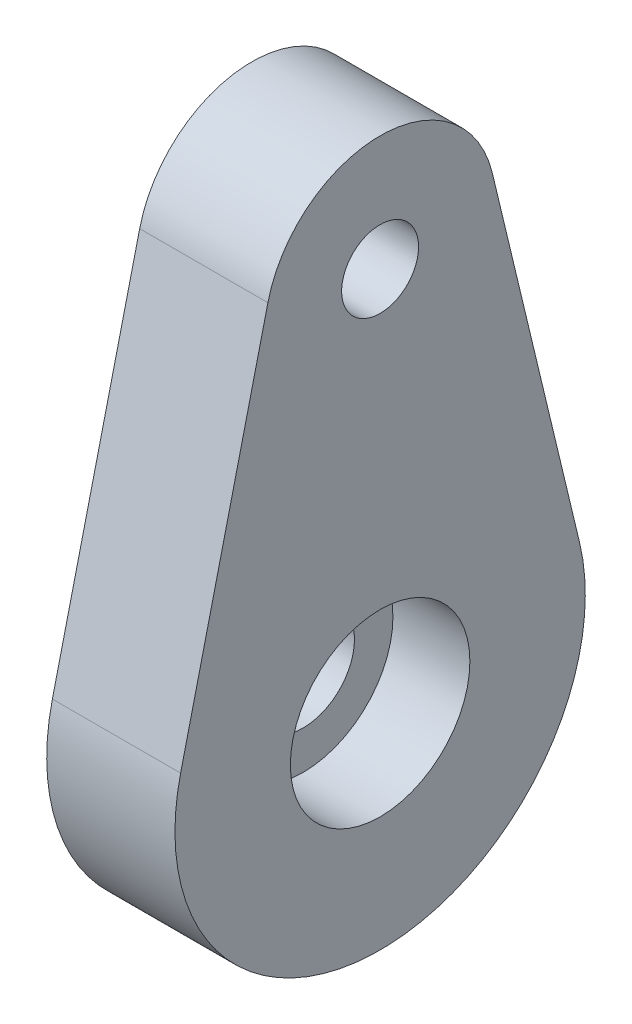
from build123d import *

# Parameters (mm, degrees)
SKETCH_1_R          = 2
SKETCH_1_R_2        = 1.5
EXTRUDE_1_DEPTH     = 5
SKETCH_2_R          = 3
SKETCH_2_R_2        = 2
EXTRUDE_2_DEPTH     = 0.5
SKETCH_3_R          = 3.5
SKETCH_3_R_2        = 2
CUT_EXTRUDE_1_DEPTH = 3


with BuildPart() as part:
    # 草图1 → 凸台-拉伸1 (new body)
    with BuildSketch(Plane(origin=(0, 0, 0), x_dir=(0, 0, -1), z_dir=(1, 0, 0))):
        with BuildLine():
            Line((-7.779174478, 1.866666667), (-4.375785644, 16.05))
            ThreePointArc((-4.375785644, 16.05), (0, 19.5), (4.375785644, 16.05))
            Line((4.375785644, 16.05), (7.779174478, 1.866666667))
            ThreePointArc((7.779174478, 1.866666667), (0, -8), (-7.779174478, 1.866666667))
        make_face()
        Circle(SKETCH_1_R, mode=Mode.SUBTRACT)
        with Locations((0, 15)):
            Circle(SKETCH_1_R_2, mode=Mode.SUBTRACT)
    extrude(amount=EXTRUDE_1_DEPTH)

    # 草图2 → 凸台-拉伸2 (add)
    with BuildSketch(Plane.ZY):
        Circle(SKETCH_2_R)
        Circle(SKETCH_2_R_2, mode=Mode.SUBTRACT)
    extrude(amount=EXTRUDE_2_DEPTH)

    # 草图3 → 切除-拉伸1 (cut)
    with BuildSketch(Plane(origin=(5, 0, 0), x_dir=(0, 0, -1), z_dir=(1, 0, 0))):
        Circle(SKETCH_3_R)
        Circle(SKETCH_3_R_2, mode=Mode.SUBTRACT)
    extrude(amount=-CUT_EXTRUDE_1_DEPTH, mode=Mode.SUBTRACT)


solid = part.part
